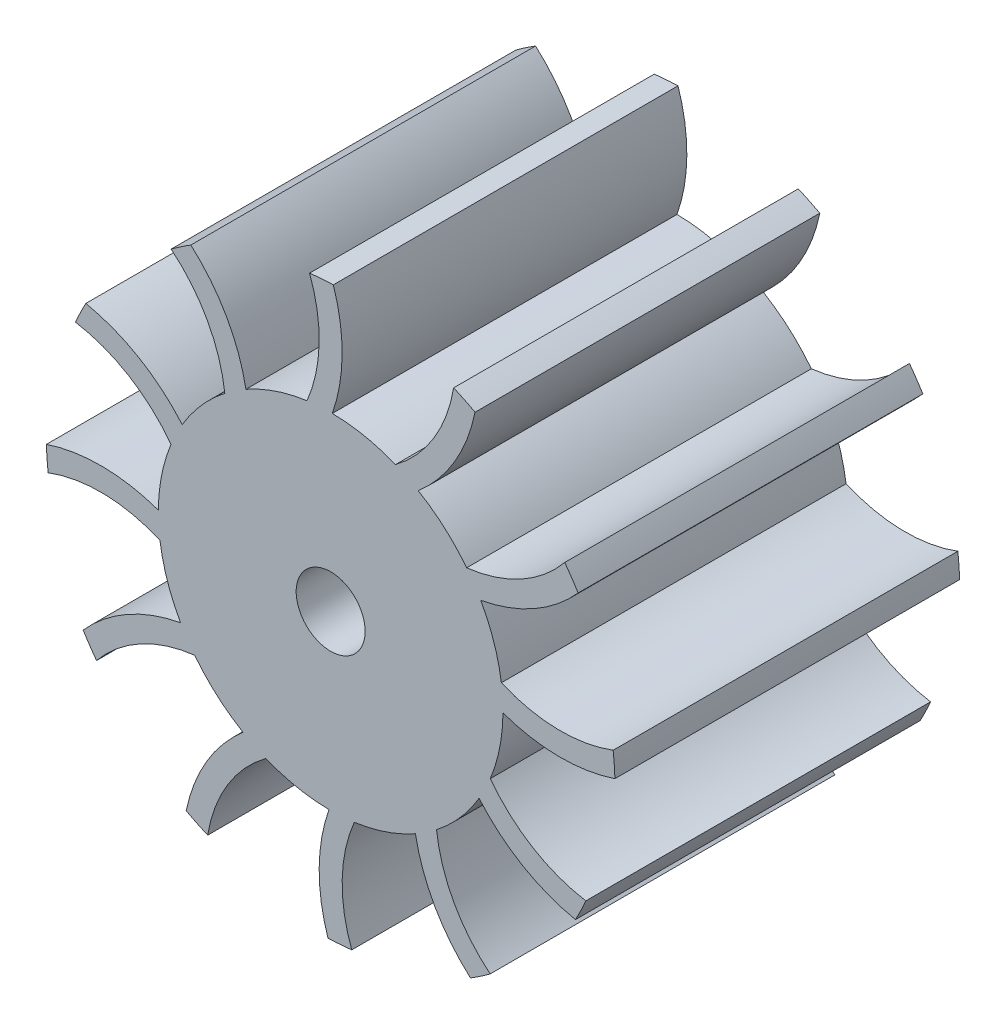
from build123d import *

# Parameters (mm, degrees)
BOSS_EXTRUDE1_DEPTH = 15
SKETCH6_R           = 15
SKETCH6_R_2         = 3
BOSS_EXTRUDE3_DEPTH = 15
CIRPATTERN3_COUNT   = 12


with BuildPart() as part:
    # Sketch1 → Boss-Extrude1 (new body, symmetric)
    with BuildSketch(Plane.XY):
        with BuildLine():
            Line((3, -13.07179677), (3, -9.801960973))
            ThreePointArc((3, -9.801960973), (-0.660686187, -16.827574978), (-0.232026419, -24.738082314))
            ThreePointArc((-0.232026419, -24.738082314), (0.803634844, -24.68419335), (1.8361294, -24.58696545))
            ThreePointArc((1.8361294, -24.58696545), (1.065897684, -18.692713773), (3, -13.07179677))
        make_face()
    boss_extrude1 = extrude(amount=BOSS_EXTRUDE1_DEPTH, both=True)

    # Sketch6 → Boss-Extrude3 (add, symmetric)
    with BuildSketch(Plane.XY):
        Circle(SKETCH6_R)
        Circle(SKETCH6_R_2, mode=Mode.SUBTRACT)
    extrude(amount=BOSS_EXTRUDE3_DEPTH, both=True)

    # CirPattern3: Boss-Extrude1 ×12 about axis
    cirpattern3_axis = Axis((0, 0, 0), (0, 0, 1))
    for i in range(1, CIRPATTERN3_COUNT):
        add(boss_extrude1.rotate(cirpattern3_axis, i * 360 / CIRPATTERN3_COUNT))


solid = part.part
